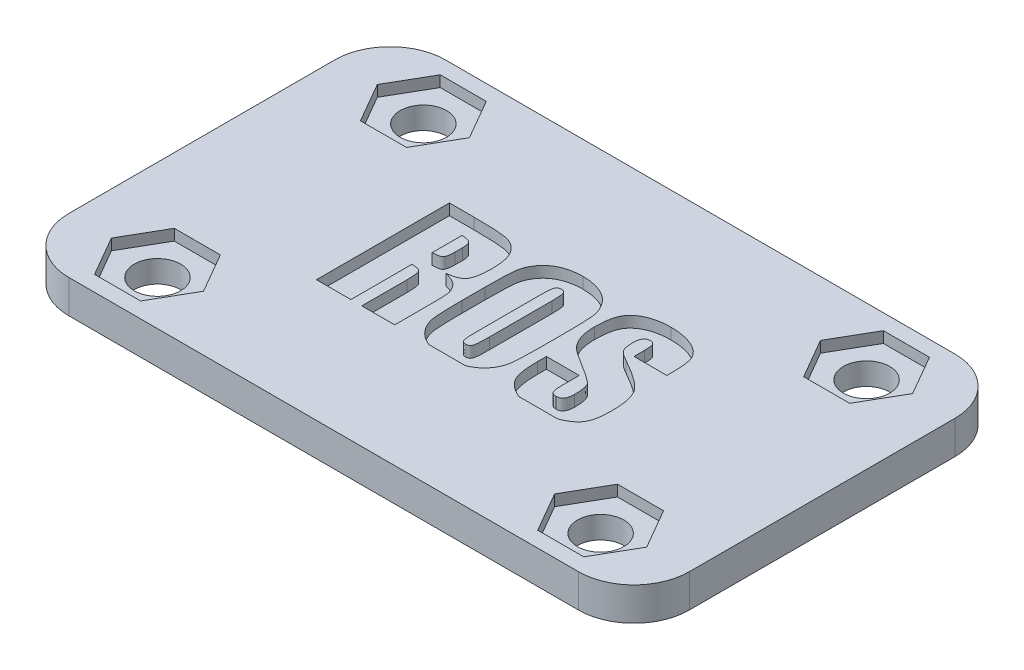
from build123d import *

# Parameters (mm, degrees)
SKETCH1_W           = 56
SKETCH1_H           = 34
BOSS_EXTRUDE1_DEPTH = 3
SKETCH2_R           = 2.09
CUT_EXTRUDE1_DEPTH  = 4
FILLET1_R           = 5
CUT_EXTRUDE2_DEPTH  = 1
CUT_EXTRUDE3_DEPTH  = 1


with BuildPart() as part:
    # Sketch1 → Boss-Extrude1 (new body)
    with BuildSketch(Plane(origin=(0, 0, 0), x_dir=(1, 0, 0), z_dir=(0, 1, 0))):
        Rectangle(SKETCH1_W, SKETCH1_H)
    extrude(amount=BOSS_EXTRUDE1_DEPTH)

    # Sketch2 → Cut-Extrude1 (cut, through all)
    with BuildSketch(Plane(origin=(0, 3, 0), x_dir=(1, 0, 0), z_dir=(0, 1, 0))):
        with Locations((-20, 12)):
            Circle(SKETCH2_R)
        with Locations((-20, -12)):
            Circle(SKETCH2_R)
    cut_extrude1 = extrude(amount=-CUT_EXTRUDE1_DEPTH, mode=Mode.SUBTRACT)

    # Mirror1: Cut-Extrude1 across plane
    add(cut_extrude1.mirror(Plane(origin=(0, 0, 0), x_dir=(0, 0, 1), z_dir=(1, 0, 0))), mode=Mode.SUBTRACT)

    # Fillet1
    fillet1_edges = [part.edges().sort_by_distance(p)[0] for p in [
        (28, 1.5, 17),
        (-28, 1.5, 17),
        (-28, 1.5, -17),
        (28, 1.5, -17),
    ]]
    fillet(fillet1_edges, radius=FILLET1_R)

    # Sketch3 → Cut-Extrude2 (cut)
    with BuildSketch(Plane(origin=(0, 3, 0), x_dir=(1, 0, 0), z_dir=(0, 1, 0))):
        Polygon((-15.843078062, 12), (-17.921539031, 15.6), (-22.078460969, 15.6), (-24.156921938, 12), (-22.078460969, 8.4), (-17.921539031, 8.4), align=None)
        Polygon((24.156921938, 12), (22.078460969, 15.6), (17.921539031, 15.6), (15.843078062, 12), (17.921539031, 8.4), (22.078460969, 8.4), align=None)
    cut_extrude2 = extrude(amount=-CUT_EXTRUDE2_DEPTH, mode=Mode.SUBTRACT)

    # Mirror2: Cut-Extrude2 across plane
    add(cut_extrude2.mirror(Plane.XY), mode=Mode.SUBTRACT)

    # Sketch4 → Cut-Extrude3 (cut)
    with BuildSketch(Plane(origin=(0, 3, 0), x_dir=(1, 0, 0), z_dir=(0, 1, 0))):
        with BuildLine():
            Line((-11.647058824, 6), (-11.647058824, -6))
            Line((-11.647058824, -6), (-8.541176471, -6))
            Line((-8.541176471, -6), (-8.541176471, -0.494117647))
            add(Edge.make_bspline(
                [(-7.552941176, -1.941176471), (-7.55424498, -1.793434227), (-7.554020614, -1.58341397), (-7.573683241, -1.318880062), (-7.590076013, -1.155345708), (-7.612410814, -1.014767423), (-7.636880862, -0.897439809), (-7.67002687, -0.803427592), (-7.707941183, -0.728735847), (-7.757338446, -0.668429063), (-7.824537904, -0.623403874), (-7.903593182, -0.580674268), (-8.000520227, -0.548006596), (-8.113232371, -0.525108006), (-8.294720985, -0.500410161), (-8.439604336, -0.494944043), (-8.541176471, -0.494117647)],
                knots=[0, 0, 0, 0, 0.208712059, 0.296134584, 0.374433717, 0.440652749, 0.497064647, 0.543362023, 0.580977914, 0.614871505, 0.652040686, 0.69429784, 0.741574127, 0.795734674, 0.856514492, 1, 1, 1, 1], degree=3))
            Line((-7.552941176, -1.941176471), (-7.552941176, -6))
            Line((-7.552941176, -6), (-4.588235294, -6))
            Line((-4.588235294, -6), (-4.588235294, -2.794852941))
            add(Edge.make_bspline(
                [(-6.315441176, 0.344117647), (-6.172093352, 0.304936482), (-5.96426666, 0.249440764), (-5.706008181, 0.152202516), (-5.541127921, 0.074358463), (-5.393138548, -0.004495553), (-5.265304109, -0.090216231), (-5.155596579, -0.180974551), (-5.038665507, -0.305339627), (-4.921183801, -0.461919551), (-4.804066298, -0.644836045), (-4.719411477, -0.821794273), (-4.669712193, -0.971938252), (-4.647812035, -1.107781346), (-4.629272011, -1.242904208), (-4.618072713, -1.414618615), (-4.606803487, -1.621960601), (-4.598564157, -1.864665754), (-4.588327404, -2.259484157), (-4.591495757, -2.573557577), (-4.588235294, -2.794852941)],
                knots=[0, 0, 0, 0, 0.110230182, 0.159227155, 0.204340897, 0.245320208, 0.283417653, 0.318243371, 0.350628895, 0.409719639, 0.463107288, 0.511383408, 0.554826309, 0.579739697, 0.613274558, 0.655916727, 0.707227072, 0.767225961, 0.835926031, 1, 1, 1, 1], degree=3))
            add(Edge.make_bspline(
                [(-4.588235294, 2.770588235), (-4.584723863, 2.559206065), (-4.599055207, 2.255955612), (-4.632076772, 1.87090442), (-4.673207777, 1.624543878), (-4.719945928, 1.405840267), (-4.778709454, 1.213812644), (-4.850581448, 1.050858542), (-4.934058256, 0.912524648), (-5.035217089, 0.796155102), (-5.155382137, 0.693854255), (-5.298502038, 0.606478943), (-5.461085168, 0.528861997), (-5.644320816, 0.463082754), (-5.929545645, 0.39053919), (-6.156717383, 0.356947017), (-6.315441176, 0.344117647)],
                knots=[0, 0, 0, 0, 0.183790359, 0.264137372, 0.336086755, 0.400975565, 0.458649469, 0.51049186, 0.555594521, 0.598692018, 0.644079697, 0.692369191, 0.744168131, 0.800636925, 0.861471696, 1, 1, 1, 1], degree=3))
            add(Edge.make_bspline(
                [(-9.410294118, 6), (-9.066880201, 6.001243961), (-8.574857998, 5.995513207), (-7.949168616, 5.977062113), (-7.547535658, 5.960609907), (-7.190863736, 5.936259375), (-6.879679639, 5.908141226), (-6.613760499, 5.876288127), (-6.38650864, 5.836754574), (-6.186213653, 5.785322173), (-6.001353394, 5.717766029), (-5.824470148, 5.63737086), (-5.657624021, 5.536919068), (-5.501987443, 5.418985599), (-5.351997549, 5.289361362), (-5.215489222, 5.138758622), (-5.084141227, 4.974264677), (-4.965409359, 4.786610968), (-4.864999337, 4.57357362), (-4.778816351, 4.335772757), (-4.708904788, 4.072150947), (-4.654769907, 3.783071634), (-4.599269123, 3.34740238), (-4.591487244, 3.00593267), (-4.588235294, 2.770588235)],
                knots=[0, 0, 0, 0, 0.148881435, 0.213302999, 0.271376625, 0.323137581, 0.368275921, 0.406826982, 0.439217091, 0.468211877, 0.496345732, 0.524443445, 0.552325136, 0.580568943, 0.609027807, 0.638127546, 0.668547056, 0.700208954, 0.734143472, 0.770447799, 0.809729999, 0.852243566, 0.897872275, 1, 1, 1, 1], degree=3))
            Line((-9.410294118, 6), (-11.647058824, 6))
        make_face()
        with BuildLine():
            Line((-8.541176471, 1.341176471), (-8.541176471, 4.023529412))
            add(Edge.make_bspline(
                [(-7.552941176, 3.092647059), (-7.554537931, 3.251002169), (-7.565481311, 3.472940592), (-7.659978959, 3.725390055), (-7.758637435, 3.853213149), (-7.900717911, 3.931351376), (-8.158362215, 4.014798629), (-8.382847434, 4.020472399), (-8.541176471, 4.023529412)],
                knots=[0, 0, 0, 0, 0.296724354, 0.405999103, 0.497474067, 0.590179394, 0.702696619, 1, 1, 1, 1], degree=3))
            Line((-7.552941176, 3.092647059), (-7.552941176, 2.428676471))
            add(Edge.make_bspline(
                [(-8.541176471, 1.341176471), (-8.38512274, 1.340256209), (-8.168150796, 1.35250807), (-7.912398621, 1.41507483), (-7.791047523, 1.467386815), (-7.718011044, 1.534265101), (-7.671056049, 1.602148806), (-7.635501399, 1.692239382), (-7.604871168, 1.800926673), (-7.581517124, 1.92947347), (-7.556060298, 2.140331025), (-7.556283288, 2.309667281), (-7.552941176, 2.428676471)],
                knots=[0, 0, 0, 0, 0.263190412, 0.361520604, 0.442777778, 0.481272857, 0.526534855, 0.58025477, 0.643242407, 0.716208439, 0.799608844, 1, 1, 1, 1], degree=3))
        make_face(mode=Mode.SUBTRACT)
        with BuildLine():
            add(Edge.make_bspline(
                [(-1.503915457, -6), (-1.531413532, -5.98929834), (-1.684264654, -5.927704401), (-1.95076289, -5.799189321), (-2.277912423, -5.576484666), (-2.573568296, -5.320969981), (-2.822324071, -5.021574955), (-3.031750417, -4.699564197), (-3.194274468, -4.358882195), (-3.310261228, -4.005311133), (-3.367983494, -3.695218378), (-3.392001619, -3.424450136), (-3.409600798, -3.185440754), (-3.424605994, -2.911118713), (-3.438310121, -2.603043809), (-3.446148111, -2.259582953), (-3.455494305, -1.732395573), (-3.458045048, -1.319122232), (-3.458823529, -1.032352941)],
                knots=[0.225245668, 0.225245668, 0.225245668, 0.225245668, 0.237119462, 0.291547555, 0.344026935, 0.396061673, 0.448382925, 0.500209986, 0.550407591, 0.599943185, 0.649656355, 0.677028621, 0.709391549, 0.746167788, 0.787661399, 0.833573904, 0.884512765, 1, 1, 1, 1], degree=3))
            Line((-1.503915457, -6), (1.785857314, -6))
            add(Edge.make_bspline(
                [(3.741176471, -1.032352941), (3.738515843, -1.312495833), (3.740020822, -1.716938729), (3.731724816, -2.233905949), (3.719084965, -2.572054799), (3.709992027, -2.876623384), (3.693852153, -3.148657165), (3.676664409, -3.387703055), (3.65173782, -3.660988472), (3.600254982, -3.974948576), (3.488281682, -4.331706733), (3.329550011, -4.671106501), (3.130316487, -4.992811996), (2.886995758, -5.287553948), (2.601574538, -5.547689803), (2.276764007, -5.771933179), (1.997531192, -5.914123278), (1.829151103, -5.983208595), (1.785857314, -6)],
                knots=[0, 0, 0, 0, 0.112808662, 0.162854343, 0.208179017, 0.249065094, 0.285542064, 0.317901769, 0.345566, 0.396043361, 0.445675688, 0.495616157, 0.546553387, 0.597655569, 0.64900077, 0.701564226, 0.756120432, 0.774811337, 0.774811337, 0.774811337, 0.774811337], degree=3))
            Line((3.741176471, -1.032352941), (3.741176471, 1.032352941))
            add(Edge.make_bspline(
                [(0.141176471, 6.282352941), (0.446866222, 6.28180272), (0.896738253, 6.24765658), (1.470246959, 6.111730635), (1.864511267, 5.973261868), (2.23164688, 5.798794134), (2.559885164, 5.577821693), (2.853640518, 5.320084012), (3.102761564, 5.02178214), (3.31135373, 4.698934941), (3.477168033, 4.359494026), (3.592660103, 4.004550036), (3.650614629, 3.693758115), (3.673474632, 3.422856702), (3.695897189, 3.184919613), (3.705660888, 2.911005186), (3.721251107, 2.603070653), (3.727534553, 2.259545334), (3.743375733, 1.732476457), (3.736621947, 1.319067176), (3.741176471, 1.032352941)],
                knots=[0, 0, 0, 0, 0.123202067, 0.180742519, 0.236944207, 0.291252849, 0.34398818, 0.39581077, 0.448142032, 0.499979007, 0.550314461, 0.599859532, 0.649873316, 0.677250819, 0.709347809, 0.74611558, 0.787617129, 0.833538417, 0.884493047, 1, 1, 1, 1], degree=3))
            add(Edge.make_bspline(
                [(-3.458823529, 1.032352941), (-3.456075957, 1.31322823), (-3.457805693, 1.717679189), (-3.449238978, 2.234635254), (-3.437049037, 2.572071909), (-3.426610332, 2.877264104), (-3.414624537, 3.149485688), (-3.396161325, 3.388406285), (-3.372075538, 3.661188279), (-3.317114102, 3.974704882), (-3.206024176, 4.331651939), (-3.047911647, 4.670886502), (-2.846415816, 4.990892446), (-2.605602554, 5.288452787), (-2.3171353, 5.54603309), (-1.994383564, 5.773013696), (-1.630010758, 5.956154381), (-1.232674465, 6.105314675), (-0.641660051, 6.244268975), (-0.176876927, 6.285588136), (0.141176471, 6.282352941)],
                knots=[0, 0, 0, 0, 0.113099886, 0.162847397, 0.208170127, 0.249054449, 0.28580995, 0.317873, 0.345536044, 0.396062444, 0.445692641, 0.495630967, 0.546314995, 0.597643479, 0.649205395, 0.701523382, 0.756077247, 0.812941755, 0.872040704, 1, 1, 1, 1], degree=3))
            Line((-3.458823529, 1.032352941), (-3.458823529, -1.032352941))
        make_face()
        with BuildLine():
            Line((-0.352941176, -2.739705882), (-0.352941176, 2.975735294))
            add(Edge.make_bspline(
                [(0.156617647, 4.305882353), (0.08085023, 4.309678464), (-0.030130312, 4.283135421), (-0.155015424, 4.200410237), (-0.217325106, 4.12626533), (-0.258701237, 4.046741945), (-0.282996931, 3.962046705), (-0.305082957, 3.855156745), (-0.321096169, 3.724480399), (-0.337768, 3.570941952), (-0.347290696, 3.318420467), (-0.354378261, 3.117770384), (-0.352941176, 2.975735294)],
                knots=[0, 0, 0, 0, 0.141272891, 0.207933505, 0.278501019, 0.320511285, 0.375555263, 0.443280697, 0.525522512, 0.622694993, 0.733336158, 1, 1, 1, 1], degree=3))
            add(Edge.make_bspline(
                [(0.635294118, 2.975735294), (0.634888044, 3.105182013), (0.631398413, 3.289759592), (0.6235986, 3.522961742), (0.61208015, 3.669288093), (0.599090521, 3.796545324), (0.584968502, 3.90514808), (0.565064682, 3.993511574), (0.537678767, 4.083590733), (0.487313622, 4.172403581), (0.368217052, 4.285835529), (0.237824485, 4.303478067), (0.156617647, 4.305882353)],
                knots=[0, 0, 0, 0, 0.245381507, 0.350013726, 0.44228014, 0.523562531, 0.592561096, 0.649714338, 0.695120491, 0.770678918, 0.840725622, 1, 1, 1, 1], degree=3))
            Line((0.635294118, 2.975735294), (0.635294118, -2.649264706))
            add(Edge.make_bspline(
                [(0.134558824, -4.305882353), (0.225500984, -4.307455811), (0.36706389, -4.277722885), (0.494908144, -4.144602582), (0.542206523, -4.036496999), (0.570377227, -3.927499228), (0.585998803, -3.817901684), (0.601673766, -3.684081413), (0.615001558, -3.525198158), (0.622614184, -3.341222749), (0.632256397, -3.046405728), (0.634422177, -2.813240363), (0.635294118, -2.649264706)],
                knots=[0, 0, 0, 0, 0.145035585, 0.209346918, 0.281953002, 0.327186926, 0.385477675, 0.455016533, 0.53818829, 0.634996402, 0.743261766, 1, 1, 1, 1], degree=3))
            add(Edge.make_bspline(
                [(-0.352941176, -2.739705882), (-0.350226697, -2.900732099), (-0.351902991, -3.129454006), (-0.343716427, -3.417079057), (-0.33103258, -3.594119508), (-0.322217486, -3.745944932), (-0.306286023, -3.87244942), (-0.289579997, -3.973508988), (-0.265715298, -4.071863646), (-0.216192568, -4.167337858), (-0.089809993, -4.285867095), (0.047774547, -4.305413233), (0.134558824, -4.305882353)],
                knots=[0, 0, 0, 0, 0.263965983, 0.374910105, 0.471520145, 0.554902094, 0.624118814, 0.680393612, 0.722784308, 0.789641701, 0.853612109, 1, 1, 1, 1], degree=3))
        make_face(mode=Mode.SUBTRACT)
        with BuildLine():
            add(Edge.make_bspline(
                [(6.650651789, -6), (6.576252329, -5.972827398), (6.422233303, -5.912399373), (6.199763722, -5.800584964), (5.983806655, -5.675489406), (5.78565489, -5.542067801), (5.607336472, -5.399445985), (5.44781206, -5.249774868), (5.30766011, -5.090501323), (5.18907327, -4.921634358), (5.085166738, -4.747578927), (5.005705599, -4.55967121), (4.940201183, -4.359199308), (4.881525476, -4.141557825), (4.837808383, -3.90363272), (4.796825675, -3.646413871), (4.767030986, -3.369567311), (4.736701537, -2.961603426), (4.729550781, -2.645664596), (4.729411765, -2.428676471)],
                knots=[0.286183202, 0.286183202, 0.286183202, 0.286183202, 0.324626854, 0.366463546, 0.406943511, 0.445764357, 0.48234487, 0.51770616, 0.551866298, 0.585155068, 0.617796039, 0.650099364, 0.683972791, 0.720174947, 0.759459361, 0.801373688, 0.846639763, 0.894618483, 1, 1, 1, 1], degree=3))
            Line((6.650651789, -6), (10.115403276, -6))
            add(Edge.make_bspline(
                [(11.929411765, -2.925), (11.930602851, -3.127359088), (11.920950761, -3.420600448), (11.887705578, -3.796157388), (11.855928389, -4.046048708), (11.81127386, -4.274167783), (11.75919795, -4.481428018), (11.697888656, -4.668555369), (11.624653281, -4.836609004), (11.536518466, -4.990389164), (11.431338179, -5.134470539), (11.31002762, -5.27373907), (11.170078971, -5.406159406), (11.012538539, -5.532802402), (10.835917431, -5.650573469), (10.642150153, -5.763878238), (10.403193142, -5.886322099), (10.22344769, -5.960537987), (10.115403276, -6)],
                knots=[0, 0, 0, 0, 0.107306702, 0.155458913, 0.199906966, 0.240819393, 0.278648167, 0.313173616, 0.345123698, 0.375689955, 0.406966721, 0.43957622, 0.473499712, 0.509002183, 0.546637541, 0.585960101, 0.627987093, 0.68893065, 0.68893065, 0.68893065, 0.68893065], degree=3))
            add(Edge.make_bspline(
                [(11.366911765, -0.339705882), (11.467388617, -0.483626221), (11.594076749, -0.726879433), (11.715050468, -1.086348269), (11.793816756, -1.394553647), (11.855199277, -1.734389423), (11.914777941, -2.246776703), (11.929419401, -2.648246792), (11.929411765, -2.925)],
                knots=[0, 0, 0, 0, 0.19599711, 0.304678492, 0.423526134, 0.551406495, 0.69050554, 1, 1, 1, 1], degree=3))
            add(Edge.make_bspline(
                [(8.611764706, 1.669852941), (8.947228186, 1.484020664), (9.425665845, 1.211025159), (10.015567532, 0.832838159), (10.385123565, 0.573785258), (10.706089588, 0.331338847), (11.041135685, 0.040607573), (11.257781155, -0.181465966), (11.366911765, -0.339705882)],
                knots=[0, 0, 0, 0, 0.335277756, 0.481299959, 0.612364063, 0.729738585, 0.83271341, 1, 1, 1, 1], degree=3))
            add(Edge.make_bspline(
                [(7.702941176, 2.404411765), (7.732209013, 2.34523609), (7.794187321, 2.258091593), (7.899538133, 2.147003759), (8.005930845, 2.059032367), (8.128760833, 1.964439715), (8.329628715, 1.829531168), (8.496026728, 1.735652611), (8.611764706, 1.669852941)],
                knots=[0, 0, 0, 0, 0.16675308, 0.269572473, 0.387215686, 0.516181657, 0.662459423, 1, 1, 1, 1], degree=3))
            add(Edge.make_bspline(
                [(7.552941176, 3.344117647), (7.55161562, 3.161121898), (7.569447678, 2.841274192), (7.643396833, 2.528316218), (7.702941176, 2.404411765)],
                knots=[0, 0, 0, 0, 0.572651319, 1, 1, 1, 1], degree=3))
            add(Edge.make_bspline(
                [(8.166176471, 4.305882353), (8.075982435, 4.305190992), (7.93787599, 4.280349872), (7.790235831, 4.173817963), (7.699797555, 4.066715214), (7.631117978, 3.928407481), (7.569213418, 3.685638648), (7.548987608, 3.486526458), (7.552941176, 3.344117647)],
                knots=[0, 0, 0, 0, 0.212113464, 0.31285869, 0.41856281, 0.535755935, 0.669150346, 1, 1, 1, 1], degree=3))
            add(Edge.make_bspline(
                [(8.682352941, 3.277941176), (8.681815263, 3.458835426), (8.677610386, 3.702864694), (8.626271204, 3.985850869), (8.573775639, 4.118302282), (8.497812839, 4.206973141), (8.366635579, 4.287723175), (8.24748927, 4.308198535), (8.166176471, 4.305882353)],
                knots=[0, 0, 0, 0, 0.412842651, 0.553103389, 0.653610262, 0.733180376, 0.814494127, 1, 1, 1, 1], degree=3))
            Line((8.682352941, 3.277941176), (8.682352941, 2.329411765))
            Line((8.682352941, 2.329411765), (11.647058824, 2.329411765))
            Line((11.647058824, 2.329411765), (11.647058824, 2.8125))
            add(Edge.make_bspline(
                [(8.069117647, 6.282352941), (8.269798456, 6.279415243), (8.566256776, 6.274710542), (8.950552125, 6.226201955), (9.223037273, 6.187197961), (9.483100436, 6.12799587), (9.732641202, 6.061105367), (9.969857945, 5.97898352), (10.19399927, 5.884079268), (10.403505792, 5.78114373), (10.597847887, 5.674504486), (10.769197704, 5.554992404), (10.928249487, 5.436797326), (11.061777476, 5.303488435), (11.183758659, 5.170192484), (11.282254224, 5.026193141), (11.365124028, 4.873396521), (11.430898814, 4.703038866), (11.491009036, 4.51185311), (11.537671481, 4.292926632), (11.580496017, 4.048897364), (11.609713881, 3.776936368), (11.640266992, 3.362360662), (11.646835725, 3.037557777), (11.647058824, 2.8125)],
                knots=[0, 0, 0, 0, 0.103080501, 0.151693764, 0.19864086, 0.244219301, 0.288418896, 0.331125316, 0.372879908, 0.413199037, 0.450863398, 0.486435308, 0.520312869, 0.552324632, 0.583055083, 0.61287614, 0.641566415, 0.672036474, 0.706397787, 0.744284381, 0.786763637, 0.833460023, 0.88452287, 1, 1, 1, 1], degree=3))
            add(Edge.make_bspline(
                [(4.588235294, 2.872058824), (4.591469137, 3.088951313), (4.595649951, 3.403265266), (4.636111763, 3.805212492), (4.674769159, 4.071936454), (4.725664367, 4.315735455), (4.785636583, 4.53708152), (4.861207941, 4.733567476), (4.945890401, 4.909801897), (5.044761604, 5.069161551), (5.158176087, 5.215897807), (5.281814, 5.357758466), (5.423724284, 5.485880811), (5.577271126, 5.608766324), (5.744079956, 5.723305873), (5.926240953, 5.826604818), (6.189515803, 5.95554162), (6.550355879, 6.087962141), (7.198333167, 6.246828301), (7.714971685, 6.282143802), (8.069117647, 6.282352941)],
                knots=[0, 0, 0, 0, 0.115094371, 0.166420003, 0.214115061, 0.257929727, 0.298417601, 0.335563099, 0.369390983, 0.401957355, 0.434786392, 0.467650138, 0.501587937, 0.535990613, 0.571893796, 0.608743473, 0.646930183, 0.727243377, 0.811970216, 1, 1, 1, 1], degree=3))
            add(Edge.make_bspline(
                [(7.142647059, -0.794117647), (6.952704842, -0.678795642), (6.68126633, -0.512154202), (6.340009139, -0.292217369), (6.123455227, -0.147526728), (5.931599499, -0.016826934), (5.767000815, 0.101799492), (5.626938908, 0.207173357), (5.475082728, 0.334053594), (5.310966814, 0.503158314), (5.136100274, 0.731764664), (4.979914087, 0.994306718), (4.839351754, 1.289928873), (4.722898216, 1.624716922), (4.617201563, 2.155095081), (4.584297556, 2.577244245), (4.588235294, 2.872058824)],
                knots=[0, 0, 0, 0, 0.139496641, 0.199928992, 0.254849813, 0.302989801, 0.34564832, 0.382206877, 0.412998417, 0.469793972, 0.529711152, 0.593277583, 0.661207422, 0.734923814, 0.815133371, 1, 1, 1, 1], degree=3))
            add(Edge.make_bspline(
                [(8.675735294, -1.875), (8.612637447, -1.804104668), (8.495363817, -1.698957246), (8.312249598, -1.559417329), (8.136990394, -1.428943263), (7.930265483, -1.288054443), (7.5984814, -1.070754972), (7.329778431, -0.908910246), (7.142647059, -0.794117647)],
                knots=[0, 0, 0, 0, 0.151175118, 0.250666735, 0.367275691, 0.499710264, 0.649705358, 1, 1, 1, 1], degree=3))
            add(Edge.make_bspline(
                [(8.964705882, -3.304411765), (8.964873691, -3.138070193), (8.957433654, -2.900066366), (8.928629277, -2.598251169), (8.894916758, -2.40780393), (8.857033664, -2.239415971), (8.792666962, -2.059236572), (8.73128353, -1.938640706), (8.675735294, -1.875)],
                knots=[0, 0, 0, 0, 0.336674091, 0.481823819, 0.613233997, 0.728041636, 0.830672596, 1, 1, 1, 1], degree=3))
            add(Edge.make_bspline(
                [(8.296323529, -4.305882353), (8.398086822, -4.308625617), (8.547260153, -4.277817789), (8.713029854, -4.1688445), (8.806461797, -4.053004916), (8.880317915, -3.908288483), (8.948485806, -3.656866318), (8.964671406, -3.450140827), (8.964705882, -3.304411765)],
                knots=[0, 0, 0, 0, 0.223295666, 0.324626749, 0.430189395, 0.546595578, 0.679609164, 1, 1, 1, 1], degree=3))
            add(Edge.make_bspline(
                [(7.694117647, -3.178676471), (7.692613474, -3.287666775), (7.700001336, -3.442679542), (7.709281996, -3.639427143), (7.726576164, -3.762661711), (7.741440691, -3.87104749), (7.767154632, -3.961855655), (7.792235706, -4.038036789), (7.832813009, -4.117699796), (7.902402961, -4.196197631), (8.056799961, -4.29037255), (8.200375126, -4.303753827), (8.296323529, -4.305882353)],
                knots=[0, 0, 0, 0, 0.221449353, 0.31585969, 0.400263121, 0.474516094, 0.538002798, 0.591926172, 0.637412015, 0.719012888, 0.801608182, 1, 1, 1, 1], degree=3))
            Line((7.694117647, -3.178676471), (7.694117647, -1.623529412))
            Line((7.694117647, -1.623529412), (4.729411765, -1.623529412))
            Line((4.729411765, -1.623529412), (4.729411765, -2.428676471))
        make_face()
    extrude(amount=-CUT_EXTRUDE3_DEPTH, mode=Mode.SUBTRACT)


solid = part.part
